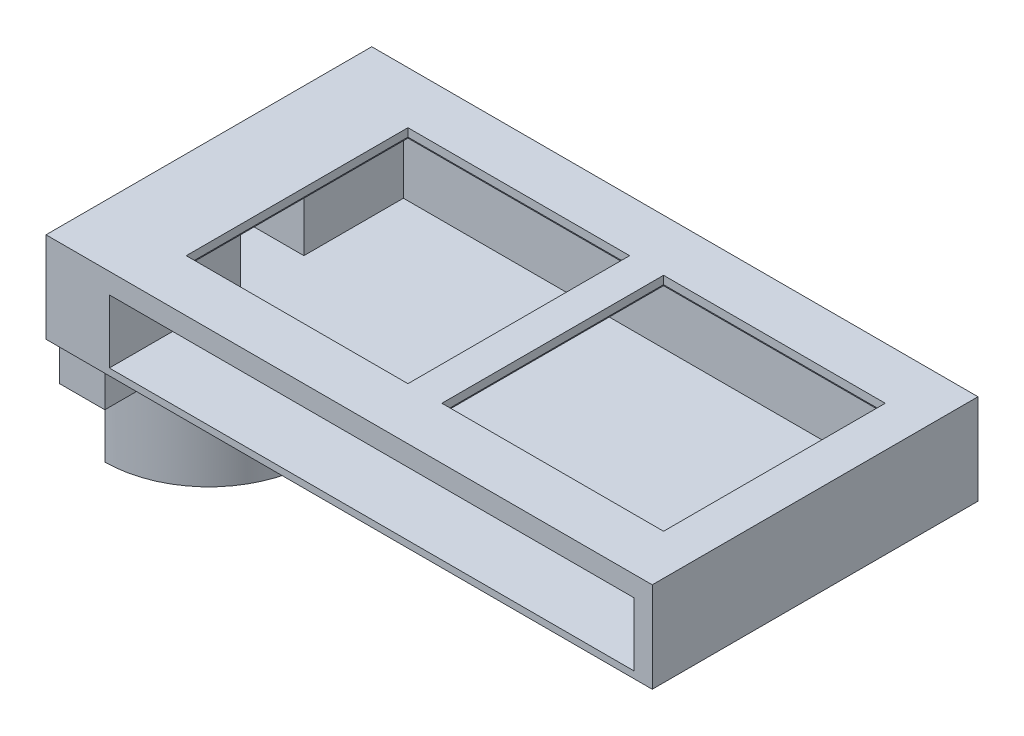
from build123d import *

# Parameters (mm, degrees)
MAIN_BODY_DEPTH            = 16
SKETCH8_W                  = 134
SKETCH8_H                  = 4
COVER_DEPTH                = 72
SKETCH20_W                 = 116
SKETCH20_H                 = 14
CRYSTAL_SLOT_DEPTH         = 65
SKETCH9_W                  = 14
SKETCH9_H                  = 14
SIPM_WINDOW_DEPTH          = 14
TUBE_ADAPTER_DEPTH         = 30
RIGHT_SCREW_TERMINAL_DEPTH = 10
RIGHT_SCREW_HOLE_REACH     = 136
SKETCH12_R                 = 1.524
LEFT_SCREW_TERMINAL_DEPTH  = 10
LEFT_SCREW_HOLE_REACH      = 136
SKETCH14_R                 = 1.524
ADAPTER_HOLE_REACH         = 146
SKETCH18_R                 = 1.524
SKETCH21_W                 = 54
SKETCH21_H                 = 54
FILTER_SLOT_DEPTH          = 2.7
SKETCH24_W                 = 49
SKETCH24_H                 = 49
FILTER_WINDOW_DEPTH        = 1.8


with BuildPart() as part:
    # Sketch5 → Main Body (new body)
    with BuildSketch(Plane(origin=(0, 0, 0), x_dir=(1, 0, 0), z_dir=(0, 1, 0))):
        Polygon((-134, 0), (-124, 0), (-1.95326153, 0), (0, 0), (0, 72), (-134, 72), align=None)
    extrude(amount=-MAIN_BODY_DEPTH)

    # Sketch8 → Cover (add)
    with BuildSketch(Plane.XY):
        with Locations((-67, -18)):
            Rectangle(SKETCH8_W, SKETCH8_H)
    extrude(amount=-COVER_DEPTH)

    # Sketch20 → Crystal Slot (cut)
    with BuildSketch(Plane.XY):
        with Locations((-62, -11.5)):
            Rectangle(SKETCH20_W, SKETCH20_H)
    extrude(amount=-CRYSTAL_SLOT_DEPTH, mode=Mode.SUBTRACT)

    # Sketch9 → SiPM Window (cut)
    with BuildSketch(Plane.ZY.offset(134)):
        with Locations((-36, -11.5)):
            Rectangle(SKETCH9_W, SKETCH9_H)
    extrude(amount=-SIPM_WINDOW_DEPTH, mode=Mode.SUBTRACT)

    # Sketch10 → Tube Adapter (add)
    with BuildSketch(Plane.XZ.offset(20)):
        with BuildLine():
            Line((-134, -13), (-134, -16))
            ThreePointArc((-134, -16), (-114, -36), (-134, -56))
            Line((-134, -56), (-134, -59))
            ThreePointArc((-134, -59), (-111, -36), (-134, -13))
        make_face()
    extrude(amount=TUBE_ADAPTER_DEPTH)

    # Sketch11 → Right Screw Terminal (add)
    with BuildSketch(Plane.XZ.offset(20)):
        with BuildLine():
            Line((-134, -59), (-134, -69))
            Line((-134, -69), (-124, -69))
            Line((-124, -69), (-124, -56.712315177))
            ThreePointArc((-124, -56.712315177), (-128.870830919, -58.420785547), (-134, -59))
        make_face()
    extrude(amount=RIGHT_SCREW_TERMINAL_DEPTH)

    # Sketch12 → Right Screw Hole (cut, up to next)
    with BuildSketch(Plane.ZY.offset(134), mode=Mode.PRIVATE) as right_screw_hole_sk1:
        with Locations((-64, -25)):
            Circle(SKETCH12_R)
    right_screw_hole_tool1 = extrude(right_screw_hole_sk1.sketch, amount=-RIGHT_SCREW_HOLE_REACH, mode=Mode.PRIVATE) & part.part
    add(right_screw_hole_tool1.solids().sort_by_distance((-134, -25, -64))[0], mode=Mode.SUBTRACT)

    # Sketch13 → Left Screw Terminal (add)
    with BuildSketch(Plane(origin=(0, -20, 0), x_dir=(-1, 0, 0), z_dir=(0, -1, 0))):
        with BuildLine():
            Line((134, 13), (134, 3))
            Line((134, 3), (124, 3))
            Line((124, 3), (124, 15.287684823))
            ThreePointArc((124, 15.287684823), (128.870830919, 13.579214453), (134, 13))
        make_face()
    extrude(amount=LEFT_SCREW_TERMINAL_DEPTH)

    # Sketch14 → Left Screw Hole (cut, up to next)
    with BuildSketch(Plane.ZY.offset(134), mode=Mode.PRIVATE) as left_screw_hole_sk1:
        with Locations((-8, -25)):
            Circle(SKETCH14_R)
    left_screw_hole_tool1 = extrude(left_screw_hole_sk1.sketch, amount=-LEFT_SCREW_HOLE_REACH, mode=Mode.PRIVATE) & part.part
    add(left_screw_hole_tool1.solids().sort_by_distance((-134, -25, -8))[0], mode=Mode.SUBTRACT)

    # Sketch18 → Adapter Hole (cut, up to next)
    with BuildSketch(Plane.ZY.offset(144), mode=Mode.PRIVATE) as adapter_hole_sk1:
        with Locations((-36, -42.5)):
            Circle(SKETCH18_R)
    adapter_hole_tool1 = extrude(adapter_hole_sk1.sketch, amount=-ADAPTER_HOLE_REACH, mode=Mode.PRIVATE) & part.part
    add(adapter_hole_tool1.solids().sort_by_distance((-144, -42.5, -36))[0], mode=Mode.SUBTRACT)

    # Sketch21 → Filter Slot (cut)
    with BuildSketch(Plane.XZ.offset(4.5)):
        with Locations((-33.5, -36)):
            Rectangle(SKETCH21_W, SKETCH21_H)
        with Locations((-90, -36)):
            Rectangle(SKETCH21_W, SKETCH21_H)
    extrude(amount=-FILTER_SLOT_DEPTH, mode=Mode.SUBTRACT)

    # Sketch24 → Filter Window (cut)
    with BuildSketch(Plane.XZ.offset(1.8)):
        with Locations((-33.5, -36)):
            Rectangle(SKETCH24_W, SKETCH24_H)
        with Locations((-90, -36)):
            Rectangle(SKETCH24_W, SKETCH24_H)
    extrude(amount=-FILTER_WINDOW_DEPTH, mode=Mode.SUBTRACT)


solid = part.part
